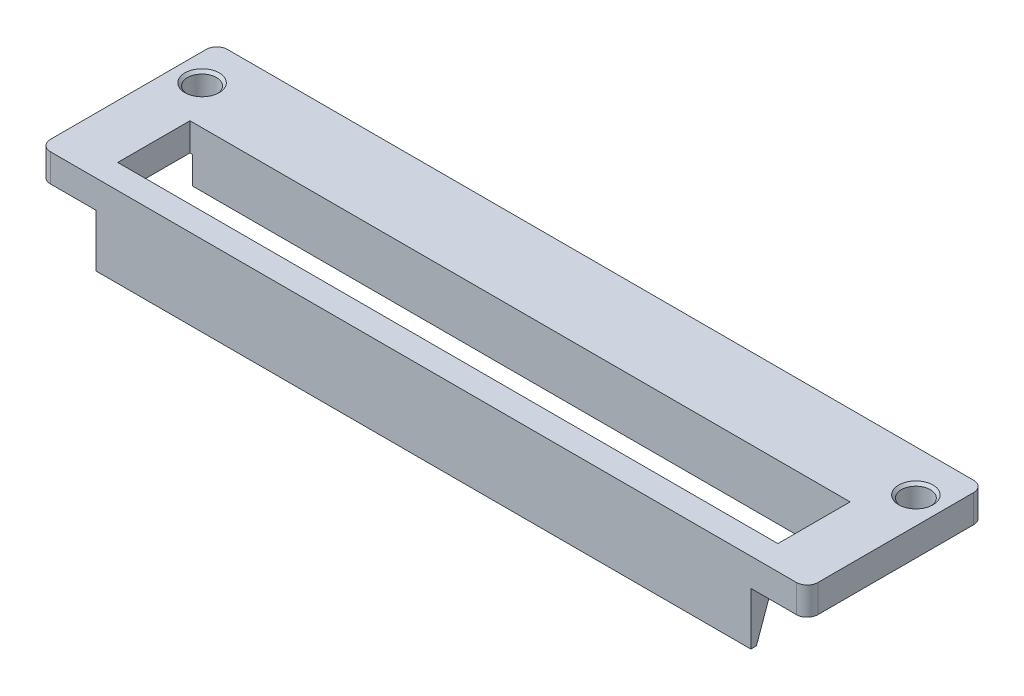
from build123d import *

# Parameters (mm, degrees)
BOSS_EXTRUDE1_DEPTH = 71.5
SKETCH2_R           = 1.35
CUT_EXTRUDE1_DEPTH  = 6.81
BOSS_EXTRUDE2_DEPTH = 2.6
BOSS_EXTRUDE3_DEPTH = 61
SKETCH5_W           = 5.25
SKETCH5_H           = 3.21
CUT_EXTRUDE2_DEPTH  = 17.5
FILLET1_R           = 1
CHAMFER1_SIZE       = 0.25


with BuildPart() as part:
    # Sketch1 → Boss-Extrude1 (new body)
    with BuildSketch(Plane(origin=(0, 0, 0), x_dir=(0, 0, -1), z_dir=(1, 0, 0))):
        Polygon((0, 0), (-7.5, 0), (-7.5, -5.15), (-6.25, -5.15), (-6.25, -5.81), (0, -5.81), align=None)
    extrude(amount=BOSS_EXTRUDE1_DEPTH)

    # Sketch2 → Cut-Extrude1 (cut, through all)
    with BuildSketch(Plane(origin=(0, 0, 0), x_dir=(1, 0, 0), z_dir=(0, 1, 0))):
        with Locations((2.5, -3.875)):
            Circle(SKETCH2_R)
        with Locations((69, -3.875)):
            Circle(SKETCH2_R)
    extrude(amount=-CUT_EXTRUDE1_DEPTH, mode=Mode.SUBTRACT)

    # Sketch3 → Boss-Extrude2 (add)
    with BuildSketch(Plane(origin=(0, 0, 0), x_dir=(1, 0, 0), z_dir=(0, 1, 0))):
        Polygon((0, -7.5), (0, -16.5), (71.5, -16.5), (71.5, -7.5), (66.5, -7.5), (66.5, -14.23), (5, -14.23), (5, -7.5), align=None)
    extrude(amount=-BOSS_EXTRUDE2_DEPTH)

    # Sketch4 → Boss-Extrude3 (add)
    with BuildSketch(Plane.ZY.offset(-5.25)):
        Polygon((16.5, -2.6), (16.5, -7.5), (15.98, -7.5), (14.23, -2.6), align=None)
    extrude(amount=-BOSS_EXTRUDE3_DEPTH)

    # Sketch5 → Cut-Extrude2 (cut, through all)
    with BuildSketch(Plane(origin=(0, 0, 0), x_dir=(-1, 0, 0), z_dir=(0, 0, -1))):
        with Locations((-2.625, -4.205)):
            Rectangle(SKETCH5_W, SKETCH5_H)
        with Locations((-68.875, -4.205)):
            Rectangle(SKETCH5_W, SKETCH5_H)
    extrude(amount=-CUT_EXTRUDE2_DEPTH, mode=Mode.SUBTRACT)

    # Fillet1
    fillet1_edges = [part.edges().sort_by_distance(p)[0] for p in [
        (71.5, -1.3, 16.5),
        (0, -1.3, 16.5),
        (0, -1.3, 0),
        (71.5, -1.3, 0),
    ]]
    fillet(fillet1_edges, radius=FILLET1_R)

    # Chamfer1
    chamfer1_edges = [part.edges().sort_by_distance(p)[0] for p in [
        (1.15, 0, 3.875),
        (67.65, 0, 3.875),
    ]]
    chamfer(chamfer1_edges, length=CHAMFER1_SIZE)


solid = part.part
